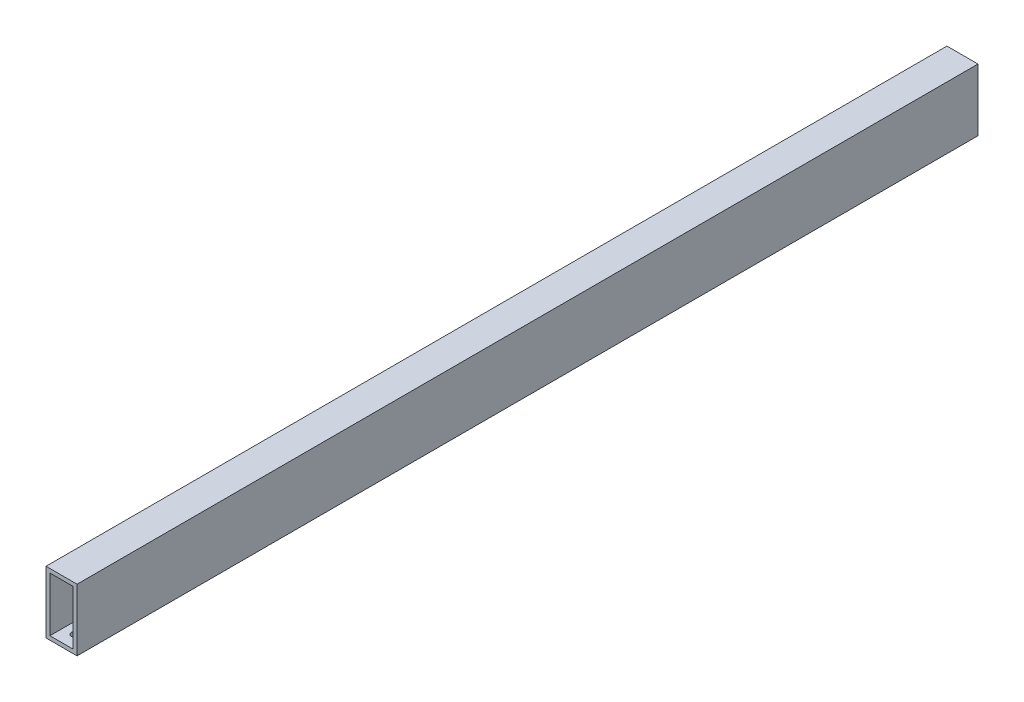
from build123d import *

# Parameters (mm, degrees)
SKETCH1_W           = 25.4
SKETCH1_H           = 50.8
SKETCH1_W_2         = 19.05
SKETCH1_H_2         = 44.45
BOSS_EXTRUDE1_DEPTH = 736.6
SKETCH4_R           = 3.175
CUT_EXTRUDE1_DEPTH  = 3.175


with BuildPart() as part:
    # Sketch1 → Boss-Extrude1 (new body)
    with BuildSketch(Plane.XY):
        with Locations((12.7, 25.4)):
            Rectangle(SKETCH1_W, SKETCH1_H)
        with Locations((12.7, 25.4)):
            Rectangle(SKETCH1_W_2, SKETCH1_H_2, mode=Mode.SUBTRACT)
    extrude(amount=BOSS_EXTRUDE1_DEPTH)

    # Sketch4 → Cut-Extrude1 (cut)
    with BuildSketch(Plane.XZ):
        with Locations((12.7, 710.541764528)):
            Circle(SKETCH4_R)
        with Locations((12.7, 725.17)):
            Circle(SKETCH4_R)
        with Locations((12.7, 11.43)):
            Circle(SKETCH4_R)
        with Locations((12.7, 26.058235472)):
            Circle(SKETCH4_R)
    extrude(amount=-CUT_EXTRUDE1_DEPTH, mode=Mode.SUBTRACT)


solid = part.part
